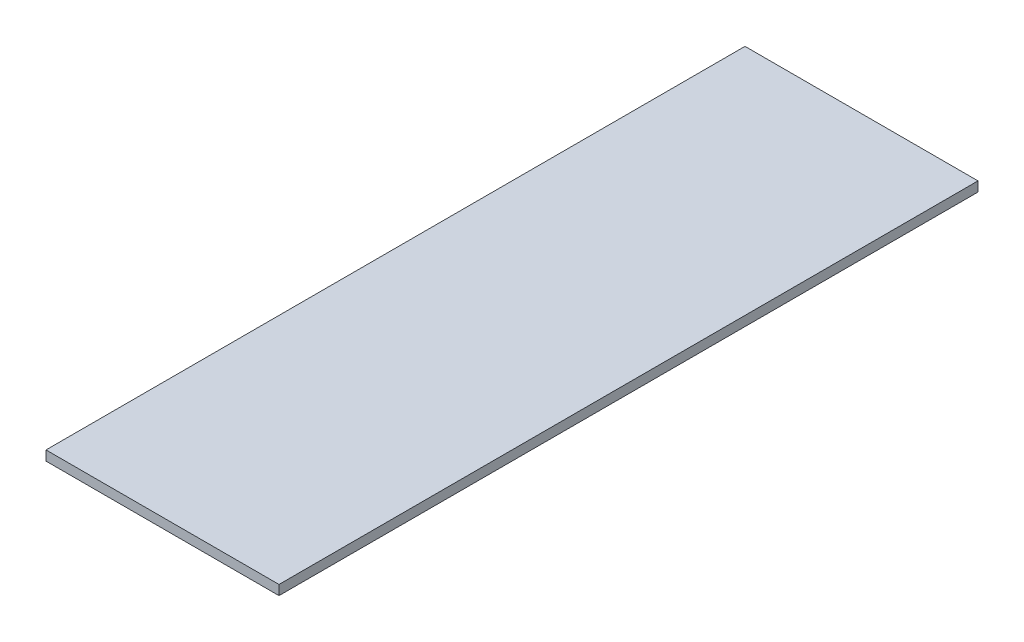
from build123d import *

# Parameters (mm, degrees)
SKETCH1_W           = 304.8
SKETCH1_H           = 914.4
BOSS_EXTRUDE1_DEPTH = 6.35


with BuildPart() as part:
    # Sketch1 → Boss-Extrude1 (new body, symmetric)
    with BuildSketch(Plane(origin=(0, 0, 0), x_dir=(1, 0, 0), z_dir=(0, 1, 0))):
        Rectangle(SKETCH1_W, SKETCH1_H)
    extrude(amount=BOSS_EXTRUDE1_DEPTH, both=True)


solid = part.part
